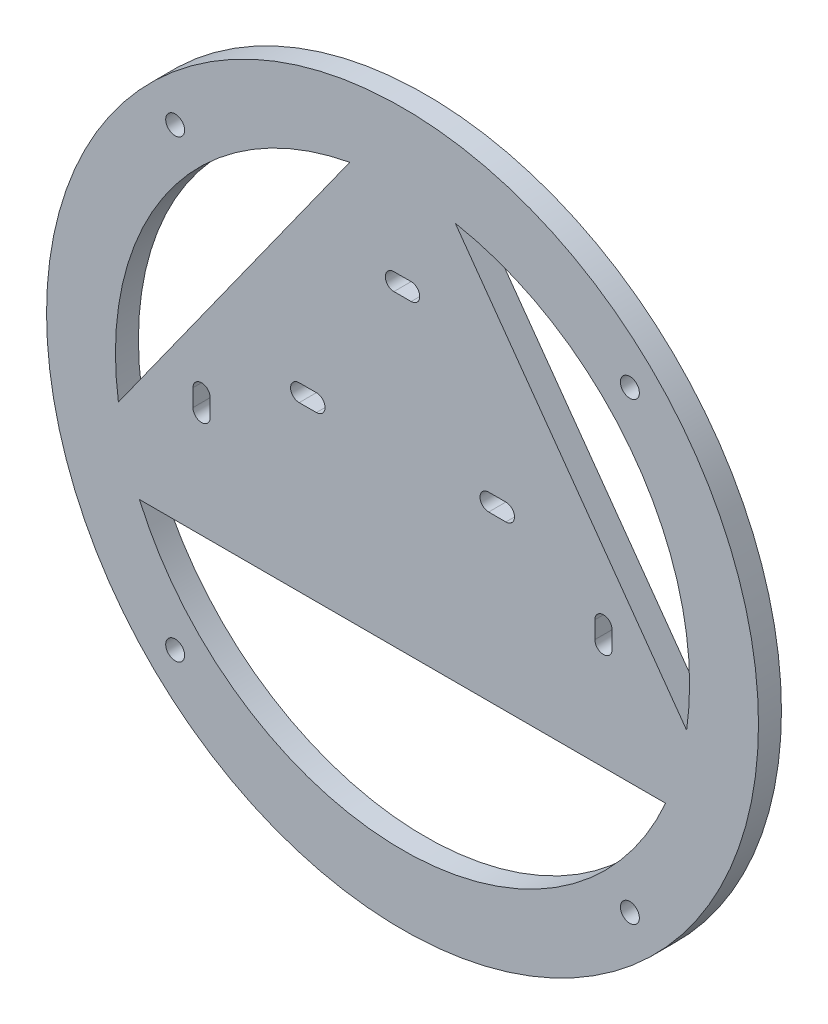
from build123d import *

# Parameters (mm, degrees)
SKETCH_1_R             = 62
EXTRUDE_1_DEPTH        = 4
HOLE_WIZARD_M4_1_D     = 3.3
HOLE_WIZARD_M4_1_DEPTH = 10.1
HOLE_WIZARD_M4_1_TIP   = 0.991420021


with BuildPart() as part:
    # 草图1 → 凸台-拉伸1 (new body)
    with BuildSketch(Plane.XY):
        Circle(SKETCH_1_R)
        with BuildLine():
            Line((-9.1948519, 49.147275596), (-49.483416864, -7.168783402))
            ThreePointArc((-49.483416864, -7.168783402), (-40.665211564, 29.091933047), (-9.1948519, 49.147275596))
        make_face(mode=Mode.SUBTRACT)
        with BuildLine():
            Line((49.483416864, -7.168783402), (9.1948519, 49.147275596))
            ThreePointArc((9.1948519, 49.147275596), (40.665211564, 29.091933047), (49.483416864, -7.168783402))
        make_face(mode=Mode.SUBTRACT)
        with BuildLine():
            Line((-45.816364164, -20.021507806), (45.816364164, -20.021507806))
            ThreePointArc((45.816364164, -20.021507806), (0, -50), (-45.816364164, -20.021507806))
        make_face(mode=Mode.SUBTRACT)
        with BuildLine():
            ThreePointArc((-33.5, -1.5), (-35, -3), (-36.5, -1.5))
            Line((-36.5, -1.5), (-36.5, 1.5))
            ThreePointArc((-36.5, 1.5), (-35, 3), (-33.5, 1.5))
            Line((-33.5, 1.5), (-33.5, -1.5))
        make_face(mode=Mode.SUBTRACT)
        with BuildLine():
            ThreePointArc((-18, 8.5), (-19.5, 10), (-18, 11.5))
            Line((-18, 11.5), (-15, 11.5))
            ThreePointArc((-15, 11.5), (-13.5, 10), (-15, 8.5))
            Line((-15, 8.5), (-18, 8.5))
        make_face(mode=Mode.SUBTRACT)
        with BuildLine():
            ThreePointArc((-1.5, 33.5), (-3, 35), (-1.5, 36.5))
            Line((-1.5, 36.5), (1.5, 36.5))
            ThreePointArc((1.5, 36.5), (3, 35), (1.5, 33.5))
            Line((1.5, 33.5), (-1.5, 33.5))
        make_face(mode=Mode.SUBTRACT)
        with BuildLine():
            Line((18, 8.5), (15, 8.5))
            ThreePointArc((15, 8.5), (13.5, 10), (15, 11.5))
            Line((15, 11.5), (18, 11.5))
            ThreePointArc((18, 11.5), (19.5, 10), (18, 8.5))
        make_face(mode=Mode.SUBTRACT)
        with BuildLine():
            ThreePointArc((33.5, 1.5), (35, 3), (36.5, 1.5))
            Line((36.5, 1.5), (36.5, -1.5))
            ThreePointArc((36.5, -1.5), (35, -3), (33.5, -1.5))
            Line((33.5, -1.5), (33.5, 1.5))
        make_face(mode=Mode.SUBTRACT)
    extrude(amount=EXTRUDE_1_DEPTH)

    # M4 螺纹孔1
    with Locations(Plane.XY.offset(4)):
        with Locations((-39.597979746, 39.597979746), (-39.597979746, -39.597979746), (39.597979746, -39.597979746), (39.597979746, 39.597979746), (84.468565782, -55.696152423), (68.880108514, -46.696152423), (6, 81), (6, 100)):
            Hole(HOLE_WIZARD_M4_1_D / 2, depth=HOLE_WIZARD_M4_1_DEPTH)
            with Locations((0, 0, -(HOLE_WIZARD_M4_1_DEPTH + HOLE_WIZARD_M4_1_TIP / 2))):  # 118° drill point
                Cone(0, HOLE_WIZARD_M4_1_D / 2, HOLE_WIZARD_M4_1_TIP, mode=Mode.SUBTRACT)


solid = part.part
